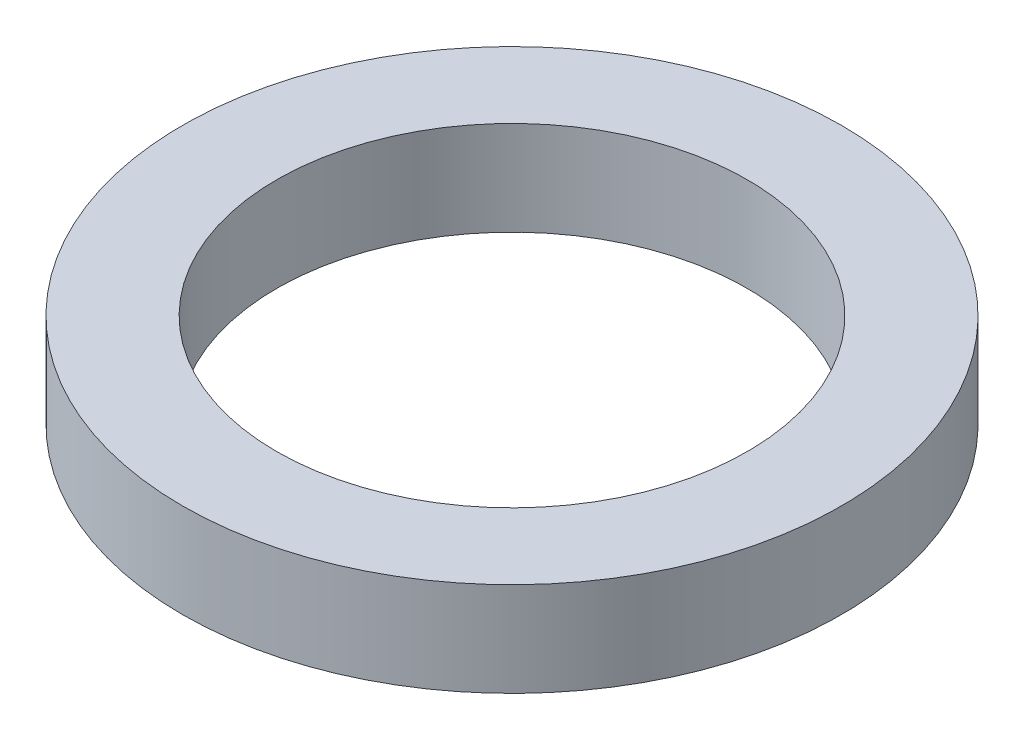
from build123d import *

# Parameters (mm, degrees)
CROQUIS1_R              = 35
CROQUIS1_R_2            = 25
SALIENTE_EXTRUIR1_DEPTH = 10


with BuildPart() as part:
    # Croquis1 → Saliente-Extruir1 (new body)
    with BuildSketch(Plane(origin=(0, 0, 0), x_dir=(1, 0, 0), z_dir=(0, 1, 0))):
        Circle(CROQUIS1_R)
        Circle(CROQUIS1_R_2, mode=Mode.SUBTRACT)
    extrude(amount=SALIENTE_EXTRUIR1_DEPTH)


solid = part.part
